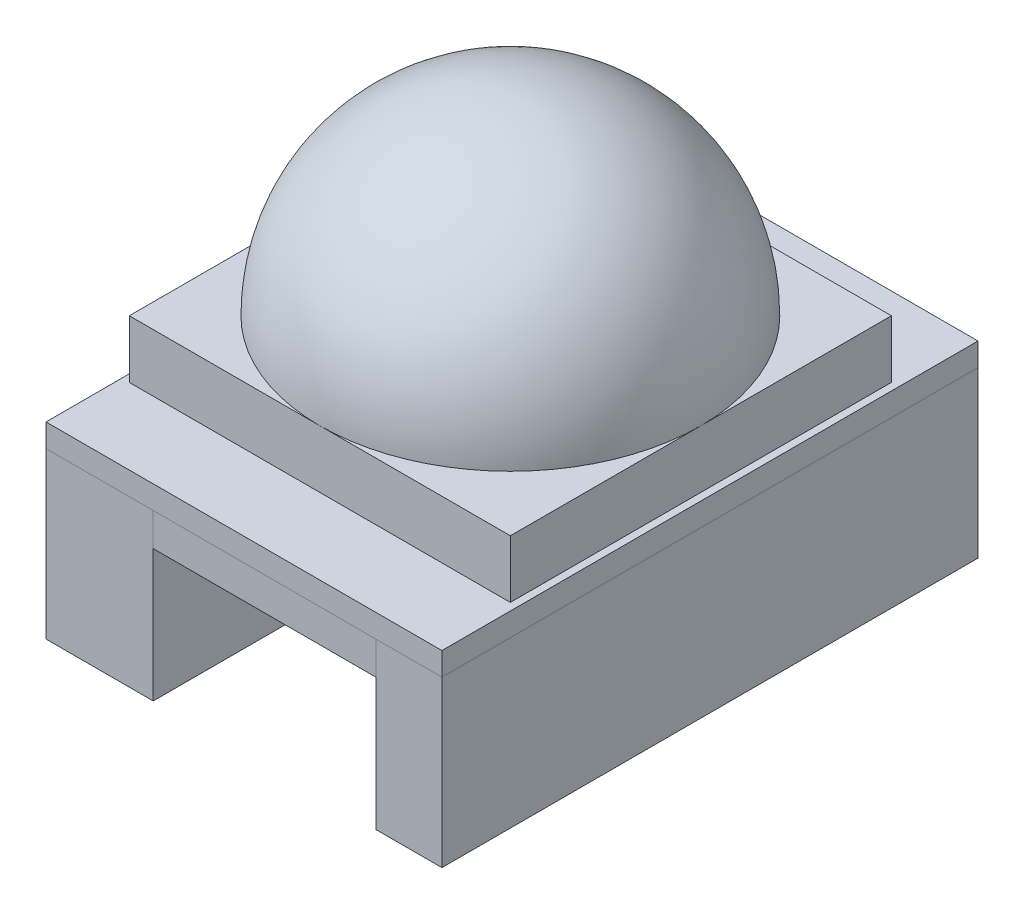
from build123d import *

# Parameters (mm, degrees)
SKETCH1_W             = 24
SKETCH1_H             = 32.5
BOSS_EXTRUDE1_DEPTH   = 1.4
SKETCH2_W             = 23.1
SKETCH2_H             = 23.1
BOSS_EXTRUDE2_DEPTH   = 3.5
SKETCH5_W             = 6.5
SKETCH5_H             = 32.5
BOSS_EXTRUDE5_DEPTH   = 10
SKETCH5_W_2           = 4
BOSS_EXTRUDE5_2_DEPTH = 10
SKETCH6_W             = 13.5
SKETCH6_H             = 32.5
BOSS_EXTRUDE6_DEPTH   = 2


with BuildPart() as part:
    # Sketch1 → Boss-Extrude1 (new body)
    with BuildSketch(Plane(origin=(0, 0, 0), x_dir=(1, 0, 0), z_dir=(0, 1, 0))):
        with Locations((1.560767591, -9.648720682)):
            Rectangle(SKETCH1_W, SKETCH1_H)
    extrude(amount=BOSS_EXTRUDE1_DEPTH)

    # Sketch2 → Boss-Extrude2 (add)
    with BuildSketch(Plane(origin=(0, 1.4, 0), x_dir=(1, 0, 0), z_dir=(0, 1, 0))):
        with Locations((1.560767591, -9.748720682)):
            Rectangle(SKETCH2_W, SKETCH2_H)
    extrude(amount=BOSS_EXTRUDE2_DEPTH)

    # Sketch4 → Revolve1 (revolve)
    with BuildSketch(Plane.XY.offset(9.748720682)):
        with BuildLine():
            Line((-9.989232409, 4.9), (1.560767591, 4.9))
            Line((1.560767591, 4.9), (1.560767591, 16.45))
            ThreePointArc((1.560767591, 16.45), (-6.606315732, 13.067083323), (-9.989232409, 4.9))
        make_face()
    revolve(axis=Axis((1.560767591, 4.9, 9.748720682), (0, 1, 0)))


with BuildPart() as body_2:
    # Sketch5 → Boss-Extrude5 (new body)
    with BuildSketch(Plane.XZ):
        with Locations((-7.189232409, 9.648720682)):
            Rectangle(SKETCH5_W, SKETCH5_H)
    extrude(amount=BOSS_EXTRUDE5_DEPTH)


with BuildPart() as body_3:
    # Sketch5 → Boss-Extrude5 2 (new body)
    with BuildSketch(Plane.XZ):
        with Locations((11.560767591, 9.648720682)):
            Rectangle(SKETCH5_W_2, SKETCH5_H)
    extrude(amount=BOSS_EXTRUDE5_2_DEPTH)


with BuildPart() as body_4:
    # Sketch6 → Boss-Extrude6 (new body)
    with BuildSketch(Plane.XZ):
        with Locations((2.810767591, 9.648720682)):
            Rectangle(SKETCH6_W, SKETCH6_H)
    extrude(amount=BOSS_EXTRUDE6_DEPTH)


solid = Compound([part.part, body_2.part, body_3.part, body_4.part])
